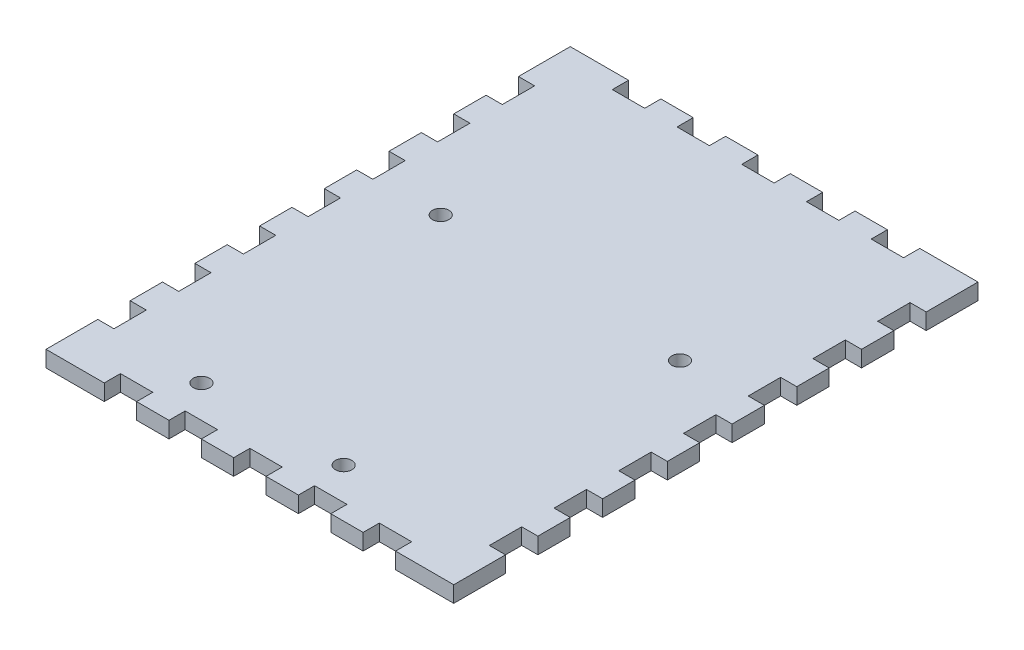
from build123d import *

# Parameters (mm, degrees)
SKETCH1_W           = 80.01
SKETCH1_H           = 102.87
BOSS_EXTRUDE1_DEPTH = 3.175
SKETCH2_W           = 3.175
SKETCH2_H           = 6.35
CUT_EXTRUDE1_DEPTH  = 4.175
SKETCH3_W           = 6.35
SKETCH3_H           = 3.175
CUT_EXTRUDE2_DEPTH  = 4.175
SKETCH8_R           = 1.60809856
SKETCH8_R_2         = 1.608098511
SKETCH8_R_3         = 1.608098562
CUT_EXTRUDE3_DEPTH  = 4.175


with BuildPart() as part:
    # Sketch1 → Boss-Extrude1 (new body)
    with BuildSketch(Plane(origin=(0, 0, 0), x_dir=(1, 0, 0), z_dir=(0, 1, 0))):
        Rectangle(SKETCH1_W, SKETCH1_H)
    extrude(amount=BOSS_EXTRUDE1_DEPTH)

    # Sketch2 → Cut-Extrude1 (cut, through all)
    with BuildSketch(Plane(origin=(0, 3.175, 0), x_dir=(1, 0, 0), z_dir=(0, 1, 0))):
        with Locations((-38.4175, -38.1)):
            Rectangle(SKETCH2_W, SKETCH2_H)
        with Locations((-38.4175, -25.4)):
            Rectangle(SKETCH2_W, SKETCH2_H)
        with Locations((-38.4175, -12.7)):
            Rectangle(SKETCH2_W, SKETCH2_H)
        with Locations((-38.4175, 0)):
            Rectangle(SKETCH2_W, SKETCH2_H)
        with Locations((-38.4175, 12.7)):
            Rectangle(SKETCH2_W, SKETCH2_H)
        with Locations((-38.4175, 25.4)):
            Rectangle(SKETCH2_W, SKETCH2_H)
        with Locations((38.4175, 25.4)):
            Rectangle(SKETCH2_W, SKETCH2_H)
        with Locations((38.4175, 12.7)):
            Rectangle(SKETCH2_W, SKETCH2_H)
        with Locations((38.4175, 0)):
            Rectangle(SKETCH2_W, SKETCH2_H)
        with Locations((38.4175, -12.7)):
            Rectangle(SKETCH2_W, SKETCH2_H)
        with Locations((38.4175, -25.4)):
            Rectangle(SKETCH2_W, SKETCH2_H)
        with Locations((38.4175, -38.1)):
            Rectangle(SKETCH2_W, SKETCH2_H)
        with Locations((-38.4175, 38.1)):
            Rectangle(SKETCH2_W, SKETCH2_H)
        with Locations((38.4175, 38.1)):
            Rectangle(SKETCH2_W, SKETCH2_H)
    extrude(amount=-CUT_EXTRUDE1_DEPTH, mode=Mode.SUBTRACT)

    # Sketch3 → Cut-Extrude2 (cut, through all)
    with BuildSketch(Plane(origin=(0, 3.175, 0), x_dir=(1, 0, 0), z_dir=(0, 1, 0))):
        with Locations((25.4, 49.8475)):
            Rectangle(SKETCH3_W, SKETCH3_H)
        with Locations((12.7, 49.8475)):
            Rectangle(SKETCH3_W, SKETCH3_H)
        with Locations((0, 49.8475)):
            Rectangle(SKETCH3_W, SKETCH3_H)
        with Locations((-12.7, 49.8475)):
            Rectangle(SKETCH3_W, SKETCH3_H)
        with Locations((-12.7, -49.8475)):
            Rectangle(SKETCH3_W, SKETCH3_H)
        with Locations((0, -49.8475)):
            Rectangle(SKETCH3_W, SKETCH3_H)
        with Locations((12.7, -49.8475)):
            Rectangle(SKETCH3_W, SKETCH3_H)
        with Locations((25.4, -49.8475)):
            Rectangle(SKETCH3_W, SKETCH3_H)
        with Locations((-25.4, -49.8475)):
            Rectangle(SKETCH3_W, SKETCH3_H)
        with Locations((-25.4, 49.8475)):
            Rectangle(SKETCH3_W, SKETCH3_H)
    extrude(amount=-CUT_EXTRUDE2_DEPTH, mode=Mode.SUBTRACT)

    # Sketch8 → Cut-Extrude3 (cut, through all)
    with BuildSketch(Plane(origin=(-2.403797872, 3.175, 1.855162727), x_dir=(0, 0, 1), z_dir=(0, 1, 0))):
        with Locations((-10.706059909, 26.514695053)):
            Circle(SKETCH8_R)
        with Locations((-11.975611322, -21.707099309)):
            Circle(SKETCH8_R_2)
        with Locations((40.054837273, -16.628893673)):
            Circle(SKETCH8_R_3)
        with Locations((40.054837273, 11.280078142)):
            Circle(SKETCH8_R)
    extrude(amount=-CUT_EXTRUDE3_DEPTH, mode=Mode.SUBTRACT)


solid = part.part
